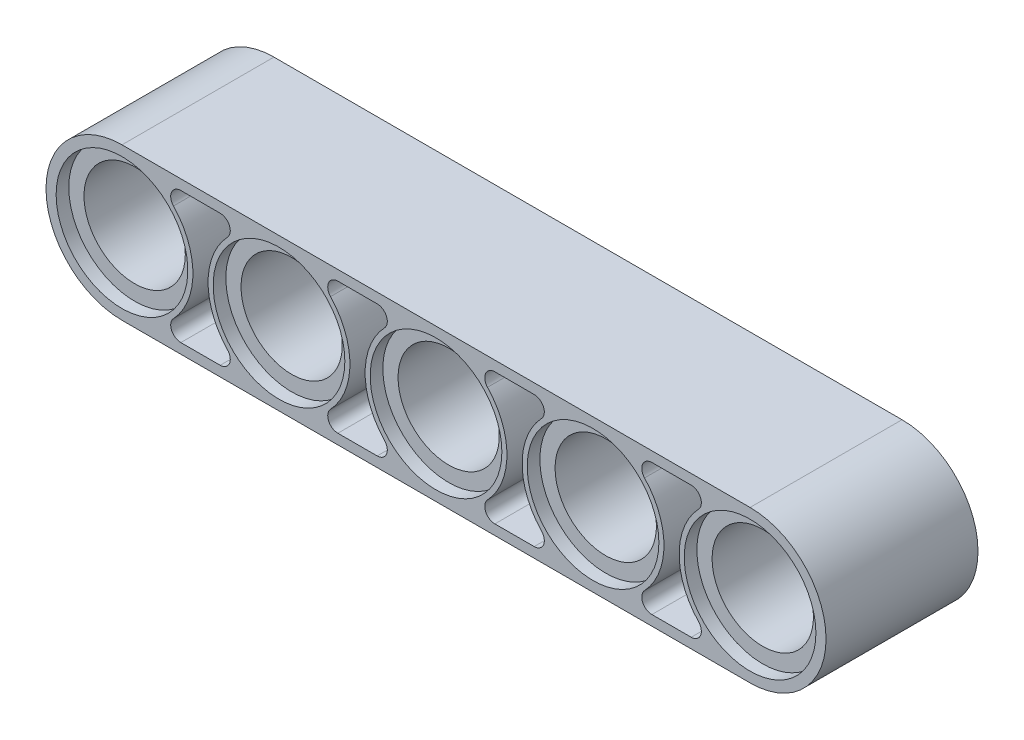
from build123d import *

# Parameters (mm, degrees)
SKETCH1_R           = 2.54
BOSS_EXTRUDE1_DEPTH = 3.81
SKETCH1_7_R         = 2.54
BOSS_EXTRUDE2_DEPTH = 3.81
SKETCH2_R           = 3.302
CUT_EXTRUDE1_DEPTH  = 0.635
LPATTERN1_COUNT     = 3
LPATTERN1_PITCH     = 7.874


with BuildPart() as part:
    # Sketch1 → Boss-Extrude1 (new body)
    with BuildSketch(Plane.XY):
        with BuildLine():
            Line((3.937, -3.81), (7.874, -3.81))
            ThreePointArc((7.874, -3.81), (11.684, 0), (7.874, 3.81))
            Line((7.874, 3.81), (3.937, 3.81))
            Line((3.937, 3.81), (3.937, 3.302))
            Line((3.937, 3.302), (4.92278669, 3.302))
            ThreePointArc((4.92278669, 3.302), (5.389414486, 2.994804631), (5.291688354, 2.44475))
            ThreePointArc((5.291688354, 2.44475), (4.318, 0), (5.291688354, -2.44475))
            ThreePointArc((5.291688354, -2.44475), (5.389414486, -2.994804631), (4.92278669, -3.302))
            Line((4.92278669, -3.302), (3.937, -3.302))
            Line((3.937, -3.302), (3.937, -3.81))
        make_face()
        with Locations((7.874, 0)):
            Circle(SKETCH1_R, mode=Mode.SUBTRACT)
    extrude(amount=BOSS_EXTRUDE1_DEPTH)


with BuildPart() as body_2:
    # Sketch1_7 → Boss-Extrude2 (new body)
    with BuildSketch(Plane.XY):
        with BuildLine():
            Line((3.937, -3.81), (3.937, -3.302))
            Line((3.937, -3.302), (2.95121331, -3.302))
            ThreePointArc((2.95121331, -3.302), (2.484585514, -2.994804631), (2.582311646, -2.44475))
            ThreePointArc((2.582311646, -2.44475), (3.556, 0), (2.582311646, 2.44475))
            ThreePointArc((2.582311646, 2.44475), (2.484585514, 2.994804631), (2.95121331, 3.302))
            Line((2.95121331, 3.302), (3.937, 3.302))
            Line((3.937, 3.302), (3.937, 3.81))
            Line((3.937, 3.81), (-3.937, 3.81))
            Line((-3.937, 3.81), (-3.937, 3.302))
            Line((-3.937, 3.302), (-2.95121331, 3.302))
            ThreePointArc((-2.95121331, 3.302), (-2.484585514, 2.994804631), (-2.582311646, 2.44475))
            ThreePointArc((-2.582311646, 2.44475), (-3.556, 0), (-2.582311646, -2.44475))
            ThreePointArc((-2.582311646, -2.44475), (-2.484585514, -2.994804631), (-2.95121331, -3.302))
            Line((-2.95121331, -3.302), (-3.937, -3.302))
            Line((-3.937, -3.302), (-3.937, -3.81))
            Line((-3.937, -3.81), (3.937, -3.81))
        make_face()
        Circle(SKETCH1_7_R, mode=Mode.SUBTRACT)
    boss_extrude2 = extrude(amount=BOSS_EXTRUDE2_DEPTH)


with BuildPart() as cut_extrude1_tool:
    # Sketch2 → Cut-Extrude1 (new body)
    with BuildSketch(Plane.XY):
        with Locations((7.874, 0)):
            Circle(SKETCH2_R)
        Circle(SKETCH2_R)
    cut_extrude1 = extrude(amount=CUT_EXTRUDE1_DEPTH)


with BuildPart() as part_1:
    add(part.part)

    # Cut-Extrude1: cut by cut_extrude1_tool
    add(cut_extrude1_tool.part, mode=Mode.SUBTRACT)


with BuildPart() as body_2_1:
    add(body_2.part)

    # Cut-Extrude1: cut by cut_extrude1_tool
    add(cut_extrude1_tool.part, mode=Mode.SUBTRACT)

    # LPattern1: Boss-Extrude2, Cut-Extrude1 ×3
    with Locations(*[(-i * LPATTERN1_PITCH, 0, 0) for i in range(1, LPATTERN1_COUNT)]):
        add(boss_extrude2)
        add(cut_extrude1, mode=Mode.SUBTRACT)


with BuildPart() as body_3:
    # Mirror2: mirrored copy
    add(part_1.part.mirror(Plane(origin=(-7.874, 0, 0), x_dir=(0, 0, 1), z_dir=(1, 0, 0))))


with BuildPart() as part_2:
    add(part_1.part)

    # Combine1: union body 3, body 2
    add(body_3.part)
    add(body_2_1.part)

    # Mirror3: part across plane


with BuildPart() as part_3:
    add(part_2.part)
    add(part_2.part.mirror(Plane.XY.offset(3.81)))


solid = part_3.part
